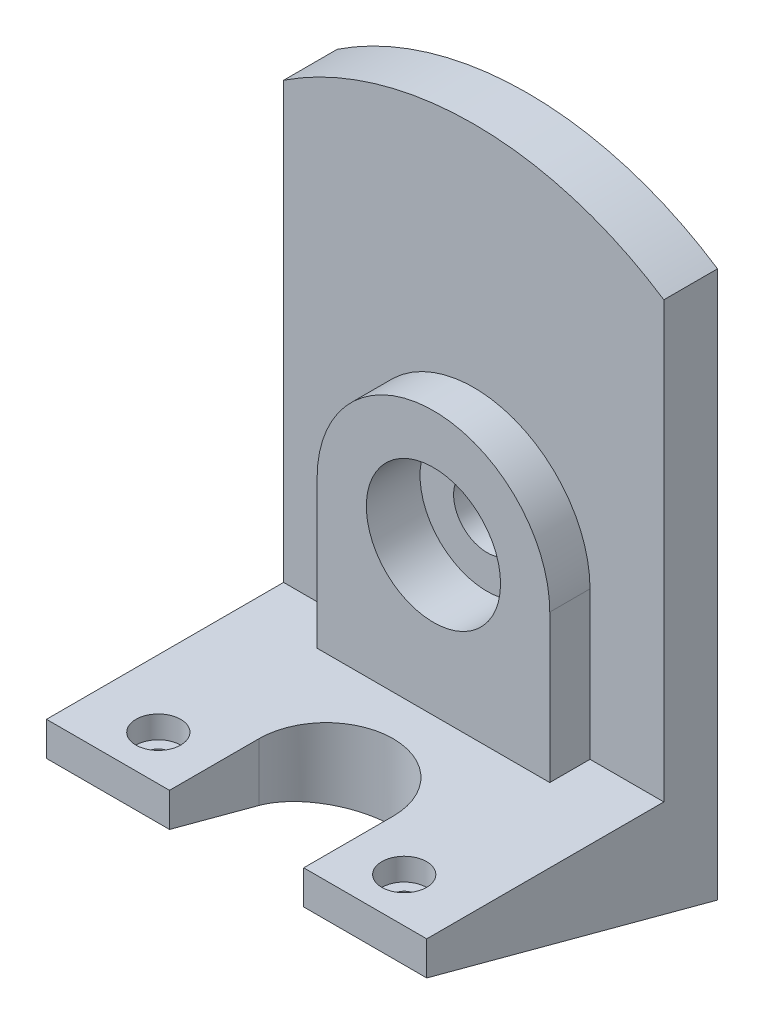
from build123d import *

# Parameters (mm, degrees)
BOSS_EXTRUDE1_DEPTH                      = 42.5
CUT_EXTRUDE1_DEPTH                       = 54
CUT_EXTRUDE1_DEPTH_BACK                  = 13
BOSS_EXTRUDE2_DEPTH                      = 9
CBORE_FOR_M10_HEX_HEAD_BOLT1_D           = 15
CBORE_FOR_M10_HEX_HEAD_BOLT1_CBORE_D     = 30
CBORE_FOR_M10_HEX_HEAD_BOLT1_CBORE_DEPTH = 12
CUT_EXTRUDE2_DEPTH                       = 111
CUT_EXTRUDE2_DEPTH_BACK                  = 26
CBORE_FOR_M10_HEX_HEAD_BOLT2_D           = 5
CBORE_FOR_M10_HEX_HEAD_BOLT2_CBORE_D     = 10
CBORE_FOR_M10_HEX_HEAD_BOLT2_CBORE_DEPTH = 5


with BuildPart() as part:
    # Sketch1 → Boss-Extrude1 (new body, symmetric)
    with BuildSketch(Plane.YZ):
        Polygon((0, 0), (17.416697508, 65), (25, 65), (25, 12), (135, 12), (135, 0), align=None)
    extrude(amount=BOSS_EXTRUDE1_DEPTH, both=True)

    # Sketch3 → Cut-Extrude1 (cut, two sides)
    with BuildSketch(Plane.XY.offset(12)) as cut_extrude1_sk:
        with BuildLine():
            Line((-299.10474982, -47.63923197), (-42.5, 122.208644278))
            ThreePointArc((-42.5, 122.208644278), (0, 135), (42.5, 122.208644278))
            Line((42.5, 122.208644278), (299.10474982, -47.63923197))
            Line((299.10474982, -47.63923197), (299.10474982, 567.80954314))
            Line((299.10474982, 567.80954314), (-299.10474982, 567.80954314))
            Line((-299.10474982, 567.80954314), (-299.10474982, -47.63923197))
        make_face()
    extrude(amount=CUT_EXTRUDE1_DEPTH, mode=Mode.SUBTRACT)
    extrude(cut_extrude1_sk.sketch, amount=-CUT_EXTRUDE1_DEPTH_BACK, mode=Mode.SUBTRACT)

    # Sketch4 → Boss-Extrude2 (add)
    with BuildSketch(Plane.XY.offset(12)):
        with BuildLine():
            Line((-26, 25), (-26, 58))
            ThreePointArc((-26, 58), (0, 84), (26, 58))
            Line((26, 58), (26, 25))
            Line((26, 25), (-26, 25))
        make_face()
    extrude(amount=BOSS_EXTRUDE2_DEPTH)

    # CBORE for M10 Hex Head Bolt1 (through all)
    with Locations(Plane(origin=(0, 58, 21), x_dir=(1, 0, 0), z_dir=(0, 0, 1))):
        with Locations((0, 0)):
            CounterBoreHole(CBORE_FOR_M10_HEX_HEAD_BOLT1_D / 2, CBORE_FOR_M10_HEX_HEAD_BOLT1_CBORE_D / 2, CBORE_FOR_M10_HEX_HEAD_BOLT1_CBORE_DEPTH)

    # Sketch8 → Cut-Extrude2 (cut, two sides)
    with BuildSketch(Plane(origin=(0, 25, 0), x_dir=(-1, 0, 0), z_dir=(0, 1, 0))) as cut_extrude2_sk:
        with BuildLine():
            Line((-15, 65), (-15, 45))
            ThreePointArc((-15, 45), (0, 30), (15, 45))
            Line((15, 45), (15, 65))
            Line((15, 65), (-15, 65))
        make_face()
    extrude(amount=CUT_EXTRUDE2_DEPTH, mode=Mode.SUBTRACT)
    extrude(cut_extrude2_sk.sketch, amount=-CUT_EXTRUDE2_DEPTH_BACK, mode=Mode.SUBTRACT)

    # CBORE for M10 Hex Head Bolt2 (through all)
    with Locations(Plane(origin=(0, 25, 0), x_dir=(-1, 0, 0), z_dir=(0, 1, 0))):
        with Locations((0, 60), (27.5, 55), (0.084967263, 59.81697493), (-27.529393087, 55.058808224)):
            CounterBoreHole(CBORE_FOR_M10_HEX_HEAD_BOLT2_D / 2, CBORE_FOR_M10_HEX_HEAD_BOLT2_CBORE_D / 2, CBORE_FOR_M10_HEX_HEAD_BOLT2_CBORE_DEPTH)


solid = part.part
